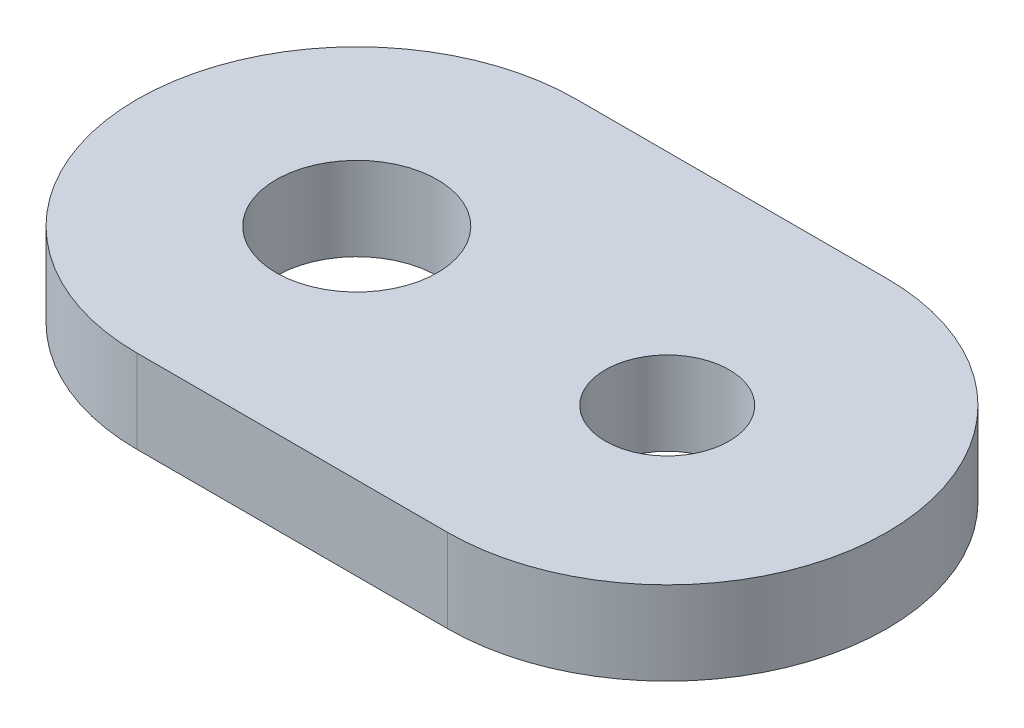
from build123d import *

# Parameters (mm, degrees)
SKETCH1_R           = 2.9
SKETCH1_R_2         = 2.225
BOSS_EXTRUDE1_DEPTH = 3


with BuildPart() as part:
    # Sketch1 → Boss-Extrude1 (new body)
    with BuildSketch(Plane.XZ.offset(3)):
        with BuildLine():
            Line((5.581105, 7.9), (-5.581105, 7.9))
            ThreePointArc((-5.581105, 7.9), (-13.481105, 0), (-5.581105, -7.9))
            Line((-5.581105, -7.9), (5.581105, -7.9))
            ThreePointArc((5.581105, -7.9), (13.481105, 0), (5.581105, 7.9))
        make_face()
        with Locations((-5.581105, 0)):
            Circle(SKETCH1_R, mode=Mode.SUBTRACT)
        with Locations((5.581105, 0)):
            Circle(SKETCH1_R_2, mode=Mode.SUBTRACT)
    extrude(amount=-BOSS_EXTRUDE1_DEPTH)


solid = part.part
